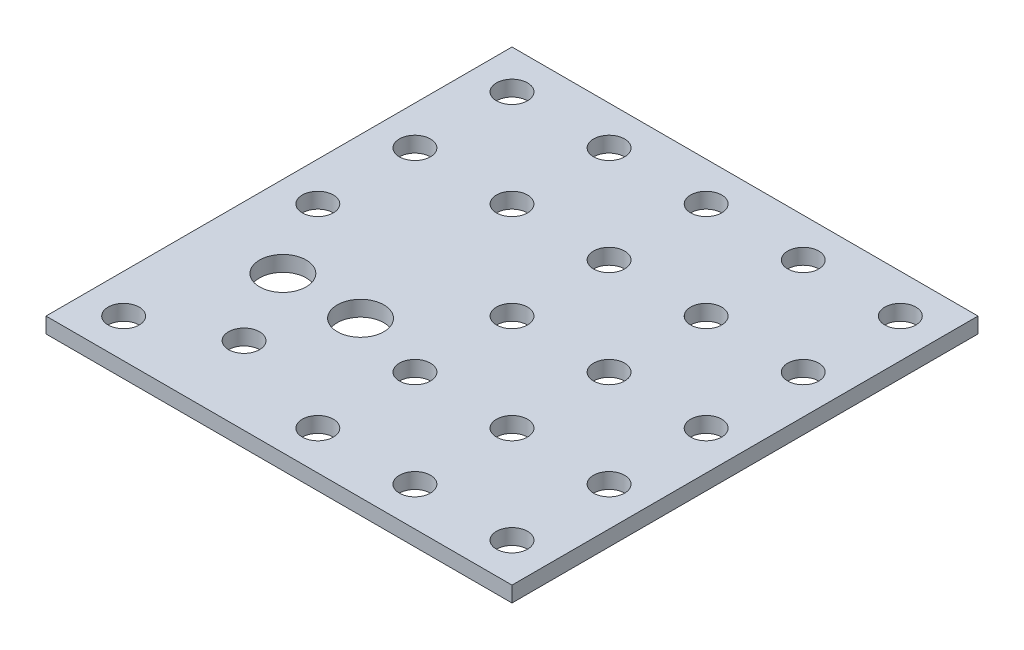
from build123d import *

# Parameters (mm, degrees)
ESQUISSE1_W             = 60
ESQUISSE1_H             = 60
BOSS_EXTRU_1_DEPTH      = 2
ESQUISSE4_R             = 3
ESQUISSE4_R_2           = 2
ENL_V_MAT_EXTRU_1_DEPTH = 10
ESQUISSE5_R             = 2
ENL_V_MAT_EXTRU_2_DEPTH = 10
ESQUISSE12_R            = 2
ENL_V_MAT_EXTRU_5_DEPTH = 2


with BuildPart() as part:
    # Esquisse1 → Boss.-Extru.1 (new body)
    with BuildSketch(Plane(origin=(0, 0, 0), x_dir=(1, 0, 0), z_dir=(0, 1, 0))):
        with Locations((30, 30)):
            Rectangle(ESQUISSE1_W, ESQUISSE1_H)
    extrude(amount=BOSS_EXTRU_1_DEPTH)

    # Esquisse4 → Enlèv. mat.-Extru.1 (cut)
    with BuildSketch(Plane(origin=(0, 2, 0), x_dir=(1, 0, 0), z_dir=(0, 1, 0))):
        with Locations(Location((10.5, 20, 0), (0, 0, 270))):  # turned: the seam where the file's is
            Circle(ESQUISSE4_R)
        with Locations(Location((20.5, 20, 0), (0, 0, 270))):  # turned: the seam where the file's is
            Circle(ESQUISSE4_R)
        with Locations(Location((15.5, 10, 0), (0, 0, 270))):  # turned: the seam where the file's is
            Circle(ESQUISSE4_R_2)
    extrude(amount=-ENL_V_MAT_EXTRU_1_DEPTH, mode=Mode.SUBTRACT)

    # Esquisse5 → Enlèv. mat.-Extru.2 (cut)
    with BuildSketch(Plane(origin=(0, 2, 0), x_dir=(1, 0, 0), z_dir=(0, 1, 0))):
        with Locations(Location((5, 5, 0), (0, 0, 270))):  # turned: the seam where the file's is
            Circle(ESQUISSE5_R)
        with Locations(Location((55, 5, 0), (0, 0, 270))):  # turned: the seam where the file's is
            Circle(ESQUISSE5_R)
        with Locations(Location((55, 55, 0), (0, 0, 270))):  # turned: the seam where the file's is
            Circle(ESQUISSE5_R)
        with Locations(Location((5, 55, 0), (0, 0, 270))):  # turned: the seam where the file's is
            Circle(ESQUISSE5_R)
        with Locations(Location((30, 55, 0), (0, 0, 270))):  # turned: the seam where the file's is
            Circle(ESQUISSE5_R)
        with Locations(Location((30, 5, 0), (0, 0, 270))):  # turned: the seam where the file's is
            Circle(ESQUISSE5_R)
        with Locations(Location((30, 30, 0), (0, 0, 270))):  # turned: the seam where the file's is
            Circle(ESQUISSE5_R)
        with Locations(Location((55, 30, 0), (0, 0, 270))):  # turned: the seam where the file's is
            Circle(ESQUISSE5_R)
        with Locations(Location((5, 30, 0), (0, 0, 270))):  # turned: the seam where the file's is
            Circle(ESQUISSE5_R)
    extrude(amount=-ENL_V_MAT_EXTRU_2_DEPTH, mode=Mode.SUBTRACT)

    # Esquisse12 → Enlèv. mat.-Extru.5 (cut)
    with BuildSketch(Plane(origin=(0, 2, 0), x_dir=(1, 0, 0), z_dir=(0, 1, 0))):
        with Locations(Location((17.5, 55, 0), (0, 0, 270))):  # turned: the seam where the file's is
            Circle(ESQUISSE12_R)
        with Locations(Location((42.5, 55, 0), (0, 0, 270))):  # turned: the seam where the file's is
            Circle(ESQUISSE12_R)
        with Locations(Location((42.5, 42.5, 0), (0, 0, 270))):  # turned: the seam where the file's is
            Circle(ESQUISSE12_R)
        with Locations(Location((17.5, 42.5, 0), (0, 0, 270))):  # turned: the seam where the file's is
            Circle(ESQUISSE12_R)
        with Locations(Location((42.5, 17.5, 0), (0, 0, 270))):  # turned: the seam where the file's is
            Circle(ESQUISSE12_R)
        with Locations(Location((55, 17.5, 0), (0, 0, 270))):  # turned: the seam where the file's is
            Circle(ESQUISSE12_R)
        with Locations(Location((55, 42.5, 0), (0, 0, 270))):  # turned: the seam where the file's is
            Circle(ESQUISSE12_R)
        with Locations(Location((42.5, 5, 0), (0, 0, 270))):  # turned: the seam where the file's is
            Circle(ESQUISSE12_R)
        with Locations(Location((42.5, 30, 0), (0, 0, 270))):  # turned: the seam where the file's is
            Circle(ESQUISSE12_R)
        with Locations(Location((5, 42.5, 0), (0, 0, 270))):  # turned: the seam where the file's is
            Circle(ESQUISSE12_R)
        with Locations(Location((30, 42.5, 0), (0, 0, 270))):  # turned: the seam where the file's is
            Circle(ESQUISSE12_R)
        with Locations(Location((30, 17.5, 0), (0, 0, 270))):  # turned: the seam where the file's is
            Circle(ESQUISSE12_R)
    extrude(amount=-ENL_V_MAT_EXTRU_5_DEPTH, mode=Mode.SUBTRACT)


solid = part.part
